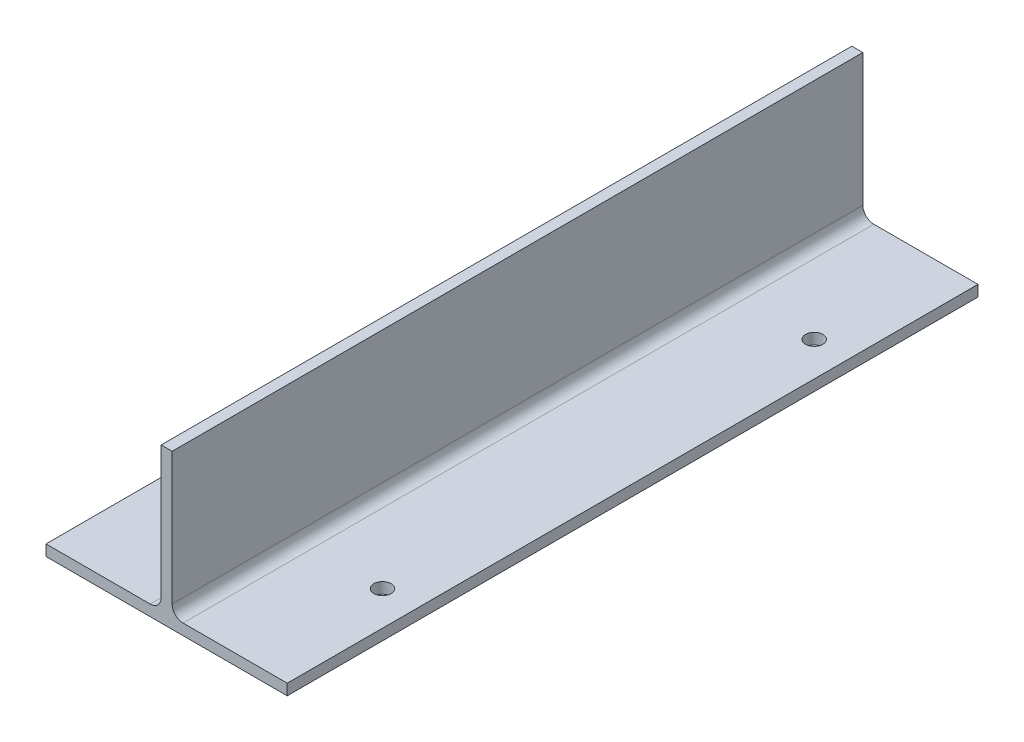
from build123d import *

# Parameters (mm, degrees)
RESSALTO_EXTRUS_O1_DEPTH = 400
ESBO_O2_R                = 5
CORTE_EXTRUS_O1_DEPTH    = 7.35


with BuildPart() as part:
    # Esboço1 → Ressalto-extrusão1 (new body)
    with BuildSketch(Plane.XY):
        with BuildLine():
            Line((-69.85, 0), (69.85, 0))
            Line((69.85, 0), (69.85, 6.35))
            Line((69.85, 6.35), (9.525, 6.35))
            ThreePointArc((9.525, 6.35), (5.034871939, 8.209871939), (3.175, 12.7))
            Line((3.175, 12.7), (3.175, 89.3))
            Line((3.175, 89.3), (-3.175, 89.3))
            Line((-3.175, 89.3), (-3.175, 12.7))
            ThreePointArc((-3.175, 12.7), (-5.034871939, 8.209871939), (-9.525, 6.35))
            Line((-9.525, 6.35), (-69.85, 6.35))
            Line((-69.85, 6.35), (-69.85, 0))
        make_face()
    extrude(amount=RESSALTO_EXTRUS_O1_DEPTH)

    # Esboço2 → Corte-extrusão1 (cut, through all)
    with BuildSketch(Plane(origin=(0, 6.35, 0), x_dir=(1, 0, 0), z_dir=(0, 1, 0))):
        with Locations((50, -75)):
            Circle(ESBO_O2_R)
        with Locations((-50, -75)):
            Circle(ESBO_O2_R)
        with Locations((50, -325)):
            Circle(ESBO_O2_R)
        with Locations((-50, -325)):
            Circle(ESBO_O2_R)
    extrude(amount=-CORTE_EXTRUS_O1_DEPTH, mode=Mode.SUBTRACT)


solid = part.part
